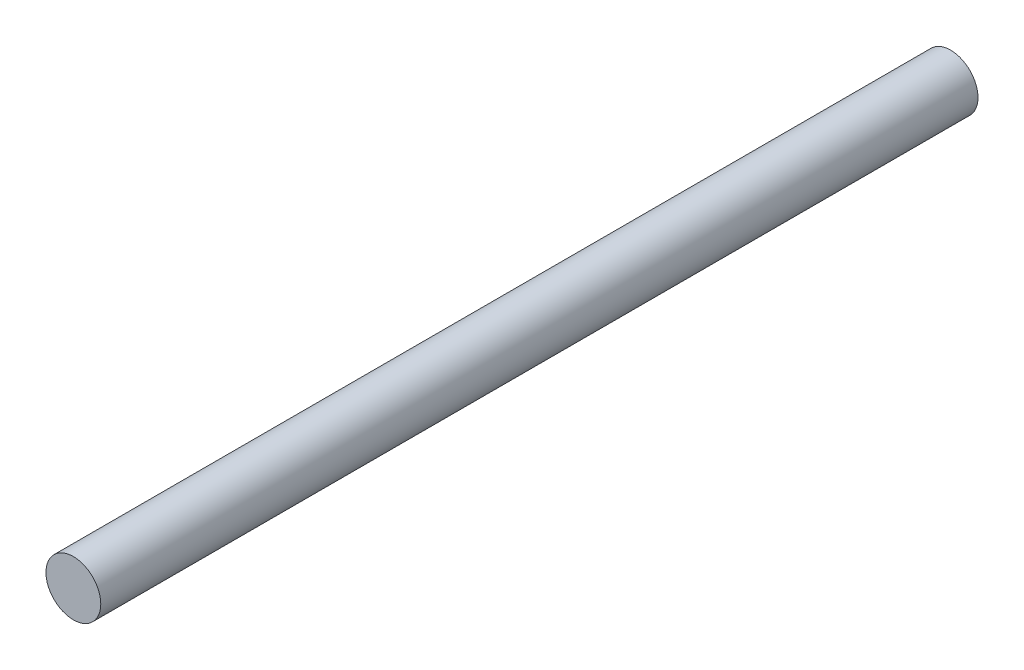
from build123d import *

# Parameters (mm, degrees)
SKETCH1_R           = 6.35
BOSS_EXTRUDE1_DEPTH = 203.2


with BuildPart() as part:
    # Sketch1 → Boss-Extrude1 (new body)
    with BuildSketch(Plane.XY):
        Circle(SKETCH1_R)
    extrude(amount=BOSS_EXTRUDE1_DEPTH)


solid = part.part
